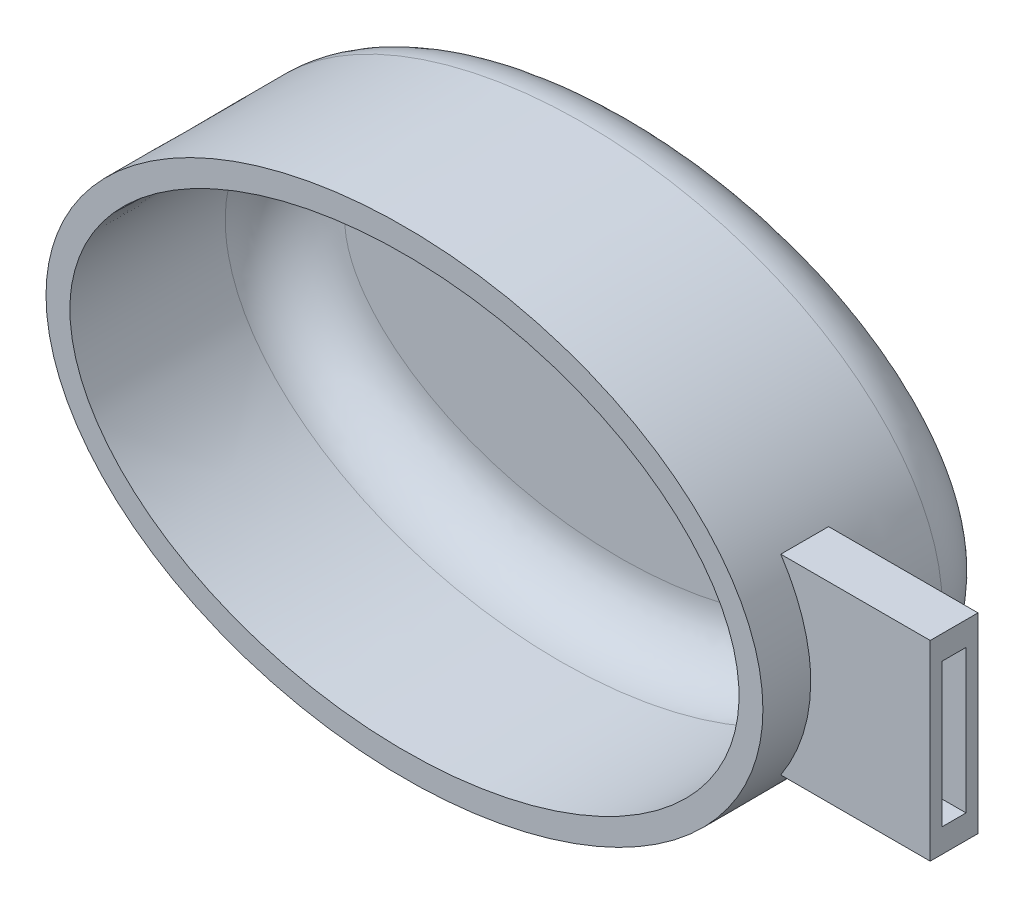
from build123d import *

# Parameters (mm, degrees)
SKETCH1_RX          = 30
SKETCH1_RY          = 20
BOSS_EXTRUDE1_DEPTH = 20
SHELL1_T            = -2
FILLET3_R           = 5
FILLET4_R           = 5
BOSS_EXTRUDE3_DEPTH = 8
CUT_EXTRUDE2_DEPTH  = 4
SKETCH12_W          = 2
SKETCH12_H          = 12
CUT_EXTRUDE3_DEPTH  = 20


with BuildPart() as part:
    # Sketch1 → Boss-Extrude1 (new body)
    with BuildSketch(Plane.XY):
        with Locations((0, 0)):
            Ellipse(SKETCH1_RX, SKETCH1_RY)
    extrude(amount=BOSS_EXTRUDE1_DEPTH)

    # Shell1
    shell1_openings = [part.faces().sort_by_distance(p)[0] for p in [
        (0, 0, 20),
    ]]
    offset(amount=SHELL1_T, openings=shell1_openings, kind=Kind.INTERSECTION)

    # Fillet3
    fillet3_edges = [part.edges().sort_by_distance(p)[0] for p in [
        (-28.000000024, 8.3e-08, 2),
    ]]
    fillet(fillet3_edges, radius=FILLET3_R)

    # Fillet4
    fillet4_edges = [part.edges().sort_by_distance(p)[0] for p in [
        (-29.999982994, -0.0212956, 0),
    ]]
    fillet(fillet4_edges, radius=FILLET4_R)

    # Sketch3 → Boss-Extrude3 (add)
    with BuildSketch(Plane.XY.offset(20)):
        with BuildLine():
            Line((40, 8), (40, -8))
            Line((40, -8), (27.49545417, -8))
            add(Edge.make_bspline(
                [(27.49545417, -8), (32.732683535, 0), (27.49545417, 8)],
                knots=[5.871668461, 5.871668461, 5.871668461, 6.694702153, 6.694702153, 6.694702153], degree=2, weights=[1, 0.916515139, 1]))
            Line((27.49545417, 8), (40, 8))
        make_face()
    extrude(amount=-BOSS_EXTRUDE3_DEPTH)

    # Sketch3_3 → Cut-Extrude2 (cut)
    with BuildSketch(Plane.XY.offset(20)):
        with BuildLine():
            Line((40, 8), (40, -8))
            Line((40, -8), (27.49545417, -8))
            add(Edge.make_bspline(
                [(27.49545417, -8), (32.732683535, 0), (27.49545417, 8)],
                knots=[5.871668461, 5.871668461, 5.871668461, 6.694702153, 6.694702153, 6.694702153], degree=2, weights=[1, 0.916515139, 1]))
            Line((27.49545417, 8), (40, 8))
        make_face()
    extrude(amount=-CUT_EXTRUDE2_DEPTH, mode=Mode.SUBTRACT)

    # Sketch12 → Cut-Extrude3 (cut)
    with BuildSketch(Plane(origin=(40, 0, 0), x_dir=(0, 0, -1), z_dir=(1, 0, 0))):
        with Locations((-14, 0)):
            Rectangle(SKETCH12_W, SKETCH12_H)
    extrude(amount=-CUT_EXTRUDE3_DEPTH, mode=Mode.SUBTRACT)


solid = part.part
